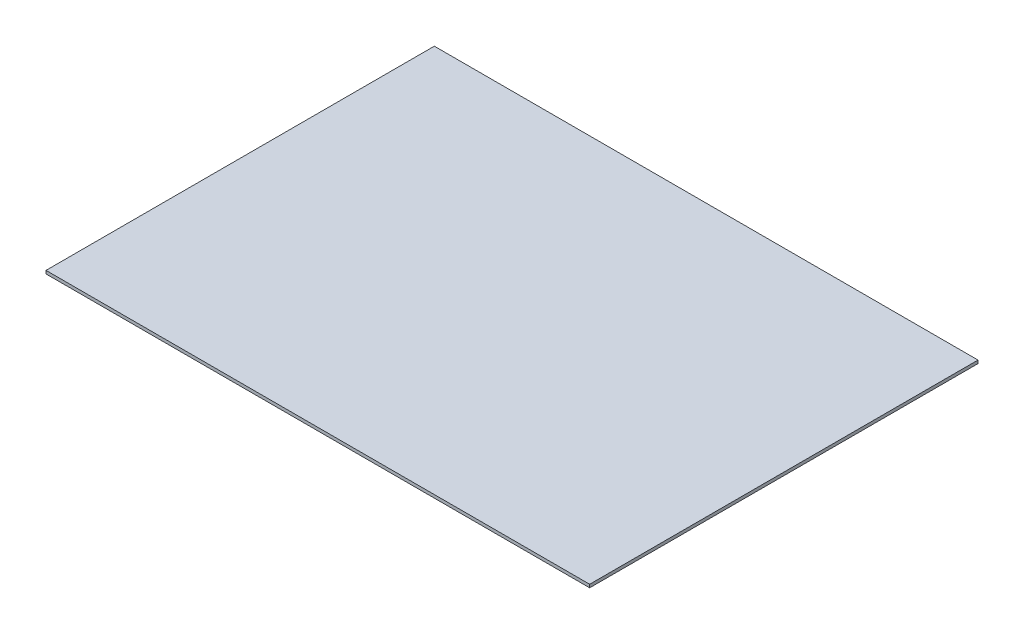
from build123d import *

# Parameters (mm, degrees)
SKETCH1_W           = 350
SKETCH1_H           = 250
BOSS_EXTRUDE1_DEPTH = 2


with BuildPart() as part:
    # Sketch1 → Boss-Extrude1 (new body)
    with BuildSketch(Plane(origin=(0, 0, 0), x_dir=(1, 0, 0), z_dir=(0, 1, 0))):
        with Locations((175, 125)):
            Rectangle(SKETCH1_W, SKETCH1_H)
    extrude(amount=BOSS_EXTRUDE1_DEPTH)


solid = part.part
